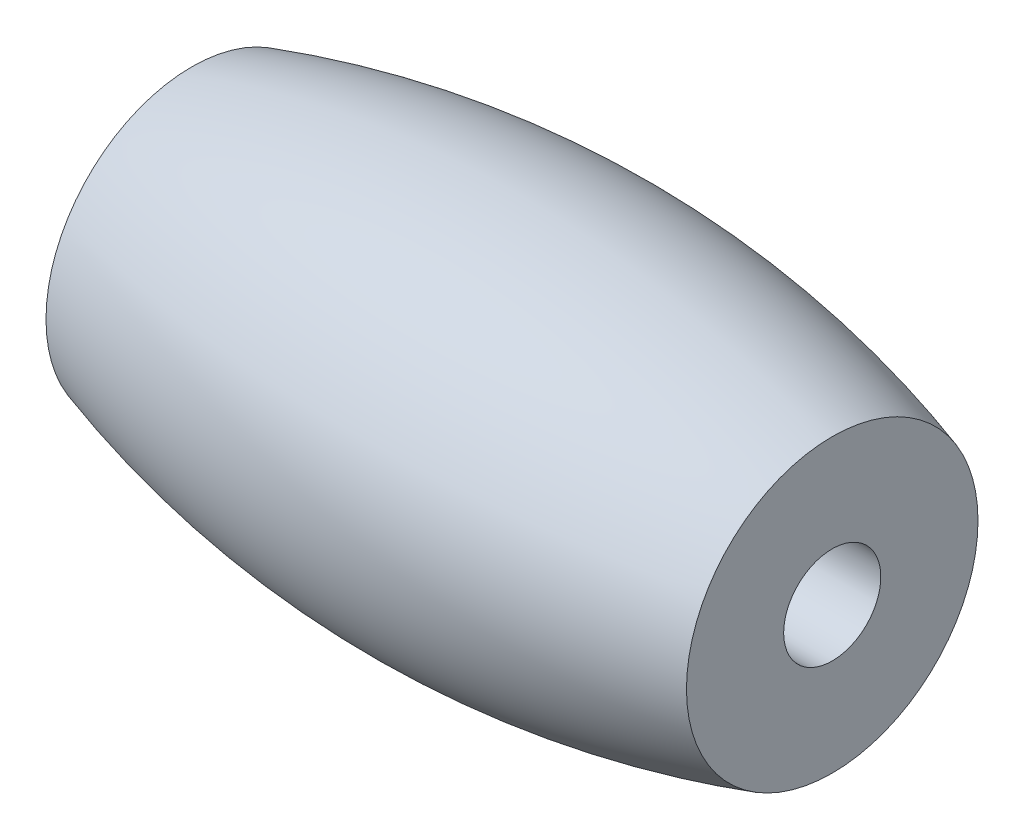
from build123d import *

# Parameters (mm, degrees)
SKETCH2_R          = 2.913907285
CUT_EXTRUDE1_DEPTH = 39.410596126


with BuildPart() as part:
    # Sketch1 → Revolve1 (revolve)
    with BuildSketch(Plane(origin=(0, 0, 0), x_dir=(1, 0, 0), z_dir=(0, 1, 0))):
        with BuildLine():
            Line((-19.205298013, 0), (19.205298013, 0))
            Line((19.205298013, 0), (19.205298013, -8.741721854))
            ThreePointArc((19.205298013, -8.741721854), (0, -11.65562914), (-19.205298013, -8.741721854))
            Line((-19.205298013, -8.741721854), (-19.205298013, 0))
        make_face()
    revolve(axis=Axis((-19.205298013, 0, 0), (1, 0, 0)))

    # Sketch2 → Cut-Extrude1 (cut, through all)
    with BuildSketch(Plane.ZY.offset(19.205298013)):
        Circle(SKETCH2_R)
    extrude(amount=-CUT_EXTRUDE1_DEPTH, mode=Mode.SUBTRACT)


solid = part.part
